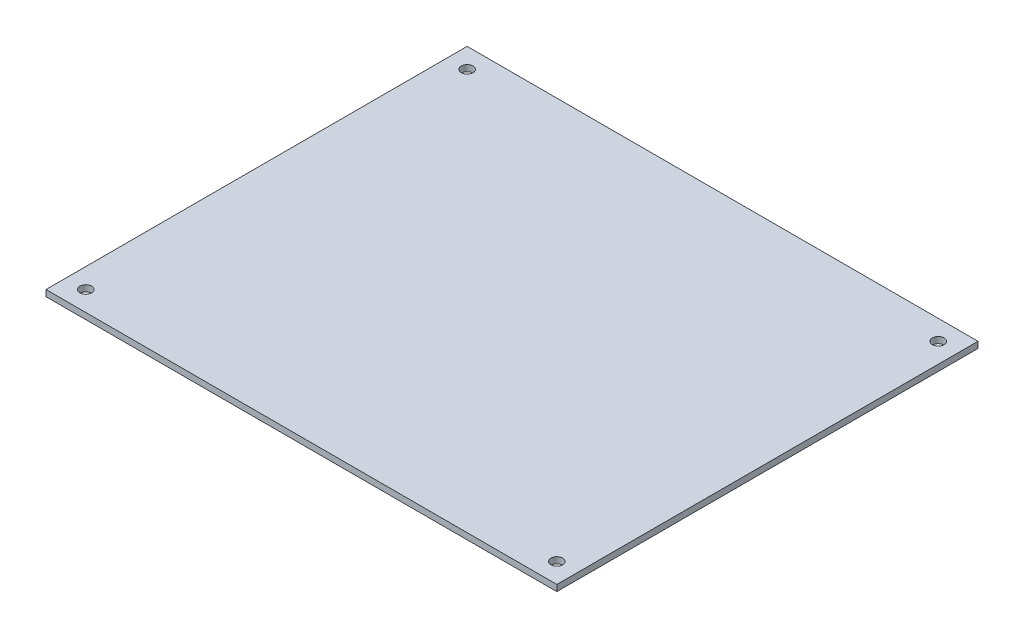
from build123d import *

# Parameters (mm, degrees)
ESBO_O1_W                = 131
ESBO_O1_H                = 108
ESBO_O1_R                = 1.5
RESSALTO_EXTRUS_O1_DEPTH = 1.6


with BuildPart() as part:
    # Esboço1 → Ressalto-extrusão1 (new body)
    with BuildSketch(Plane(origin=(0, 0, 0), x_dir=(1, 0, 0), z_dir=(0, 1, 0))):
        Rectangle(ESBO_O1_W, ESBO_O1_H)
        with Locations((-60.4, 48.9)):
            Circle(ESBO_O1_R, mode=Mode.SUBTRACT)
        with Locations((-60.4, -48.9)):
            Circle(ESBO_O1_R, mode=Mode.SUBTRACT)
        with Locations((60.4, -48.9)):
            Circle(ESBO_O1_R, mode=Mode.SUBTRACT)
        with Locations((60.4, 48.9)):
            Circle(ESBO_O1_R, mode=Mode.SUBTRACT)
    extrude(amount=RESSALTO_EXTRUS_O1_DEPTH)


solid = part.part
